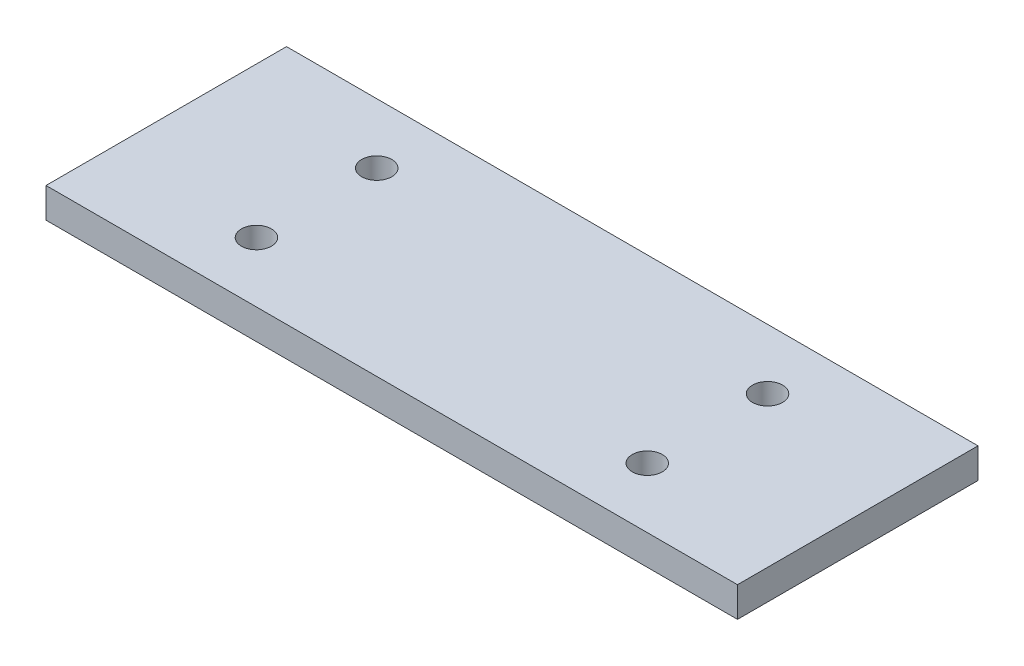
from build123d import *

# Parameters (mm, degrees)
SKETCH2_W           = 115
SKETCH2_H           = 40
SKETCH2_R           = 2.5
BOSS_EXTRUDE1_DEPTH = 2.5


with BuildPart() as part:
    # Sketch2 → Boss-Extrude1 (new body, symmetric)
    with BuildSketch(Plane(origin=(0, 0, 0), x_dir=(1, 0, 0), z_dir=(0, 1, 0))):
        Rectangle(SKETCH2_W, SKETCH2_H)
        with Locations((-32.5, 10)):
            Circle(SKETCH2_R, mode=Mode.SUBTRACT)
        with Locations((32.5, 10)):
            Circle(SKETCH2_R, mode=Mode.SUBTRACT)
        with Locations((32.5, -10)):
            Circle(SKETCH2_R, mode=Mode.SUBTRACT)
        with Locations((-32.5, -10)):
            Circle(SKETCH2_R, mode=Mode.SUBTRACT)
    extrude(amount=BOSS_EXTRUDE1_DEPTH, both=True)


solid = part.part
